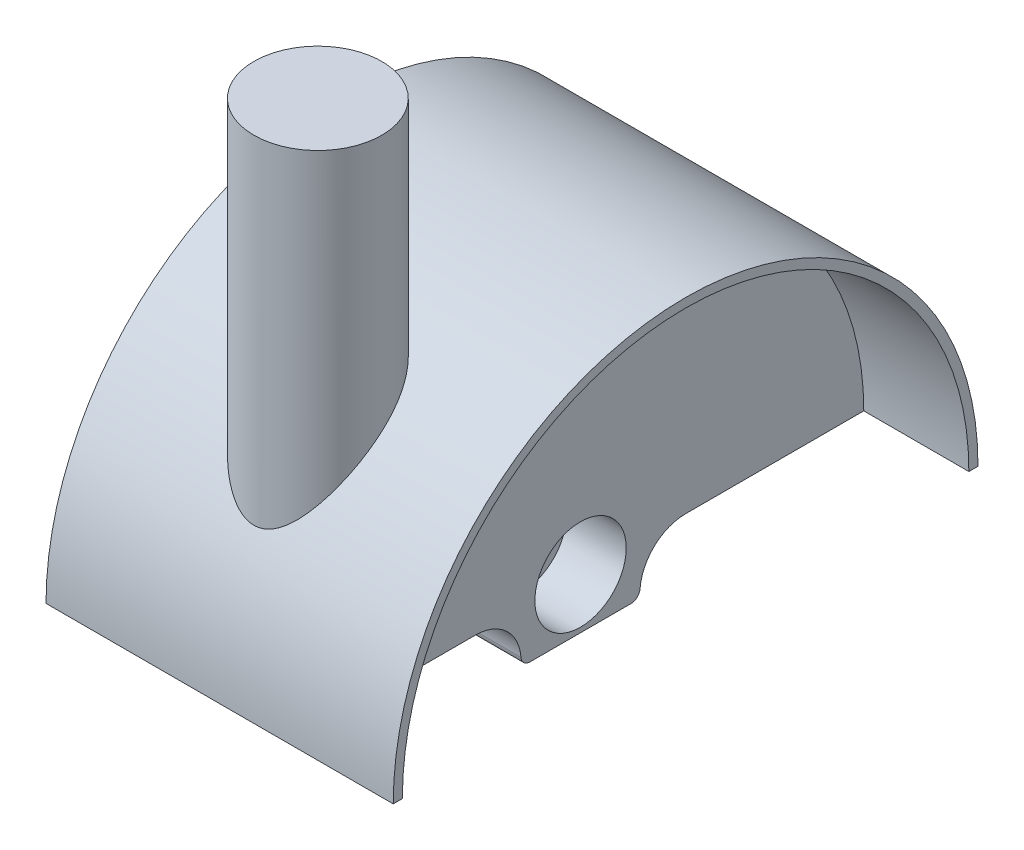
from build123d import *

# Parameters (mm, degrees)
BOSS_EXTRUDE1_DEPTH      = 19
BOSS_EXTRUDE2_DEPTH      = 7.5
SKETCH2_W                = 13
SKETCH2_H                = 5.529275222
BOSS_EXTRUDE3_DEPTH      = 7.5
SKETCH2_3_R              = 5
CUT_EXTRUDE1_DEPTH       = 6.5
FILLET2_R                = 5
FILLET3_R                = 5
FILLET4_R                = 1
BOSS_EXTRUDE4_DEPTH      = 20
BOSS_EXTRUDE4_DEPTH_BACK = 18
SKETCH3_R                = 7


with BuildPart() as part:
    # Sketch1 → Boss-Extrude1 (new body)
    with BuildSketch(Plane(origin=(0, 0, 0), x_dir=(0, 0, -1), z_dir=(1, 0, 0))):
        with BuildLine():
            ThreePointArc((32, 0), (0, 32), (-32, 0))
            Line((-32, 0), (-31, 0))
            ThreePointArc((-31, 0), (0, 31), (31, 0))
            Line((31, 0), (32, 0))
        make_face()
    extrude(amount=BOSS_EXTRUDE1_DEPTH)

    # Sketch1_3 → Boss-Extrude2 (add)
    with BuildSketch(Plane(origin=(0, 0, 0), x_dir=(0, 0, -1), z_dir=(1, 0, 0))):
        with BuildLine():
            ThreePointArc((31, 0), (0, 31), (-31, 0))
            Line((-31, 0), (31, 0))
        make_face()
    extrude(amount=BOSS_EXTRUDE2_DEPTH)

    # Sketch2 → Boss-Extrude3 (add)
    with BuildSketch(Plane(origin=(7.5, 0, 0), x_dir=(0, 0, -1), z_dir=(1, 0, 0))):
        with Locations((0, -2.764637611)):
            Rectangle(SKETCH2_W, SKETCH2_H)
    extrude(amount=-BOSS_EXTRUDE3_DEPTH)

    # Sketch2_3 → Cut-Extrude1 (cut)
    with BuildSketch(Plane(origin=(7.5, 0, 0), x_dir=(0, 0, -1), z_dir=(1, 0, 0))):
        Circle(SKETCH2_3_R)
    extrude(amount=-CUT_EXTRUDE1_DEPTH, mode=Mode.SUBTRACT)

    # Mirror2: part across plane


with BuildPart() as part_1:
    add(part.part)
    add(part.part.mirror(Plane(origin=(0, 0, 0), x_dir=(0, 0, 1), z_dir=(1, 0, 0))))

    # Fillet2
    fillet2_edges = [part_1.edges().sort_by_distance(p)[0] for p in [
        (0, 0, -6.5),
    ]]
    fillet(fillet2_edges, radius=FILLET2_R)

    # Fillet3
    fillet3_edges = [part_1.edges().sort_by_distance(p)[0] for p in [
        (0, 0, 6.5),
    ]]
    fillet(fillet3_edges, radius=FILLET3_R)

    # Fillet4
    fillet4_edges = [part_1.edges().sort_by_distance(p)[0] for p in [
        (0, -5.529275222, 6.5),
        (0, -5.529275222, -6.5),
    ]]
    fillet(fillet4_edges, radius=FILLET4_R)

    # Sketch3 → Boss-Extrude4 (add, two sides: drawn at the far end of the back side and taken through both)
    with BuildSketch(Plane(origin=(0, 32, 0), x_dir=(1, 0, 0), z_dir=(0, 1, 0)).offset(-BOSS_EXTRUDE4_DEPTH_BACK)):
        with Locations((0, -21.25)):
            Circle(SKETCH3_R)
    extrude(amount=BOSS_EXTRUDE4_DEPTH + BOSS_EXTRUDE4_DEPTH_BACK)


solid = part_1.part
